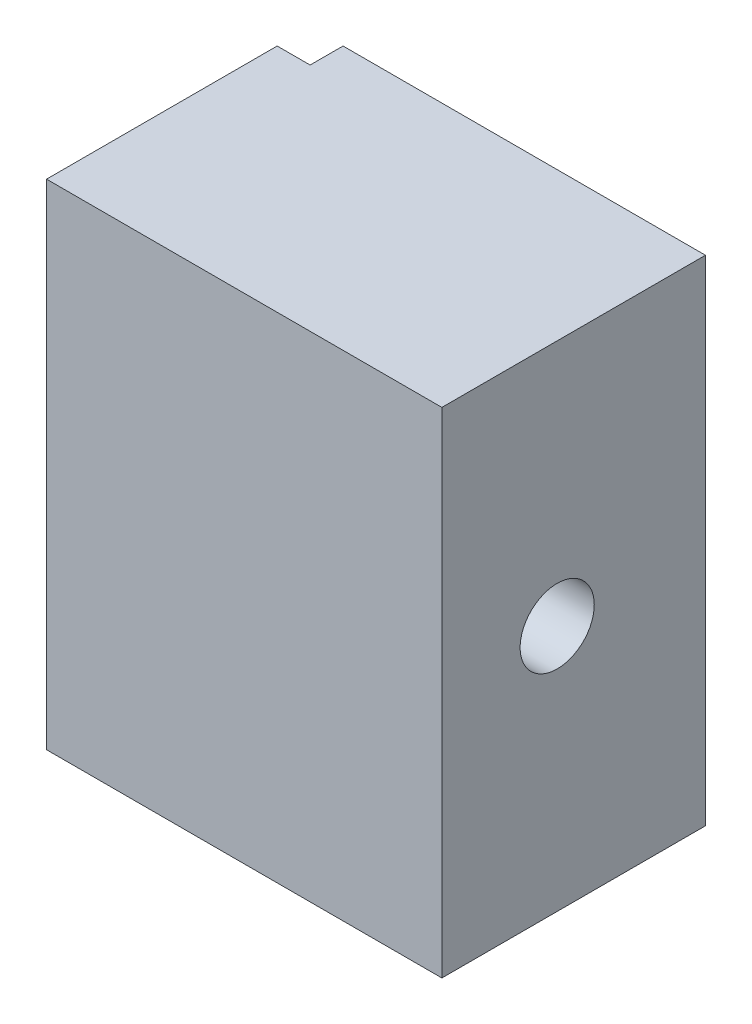
from build123d import *

# Parameters (mm, degrees)
SKETCH1_W            = 16
SKETCH1_H            = 30
BOSS_EXTRUDE1_DEPTH  = 24
SKETCH2_W            = 2
SKETCH2_H            = 30
CUT_EXTRUDE1_DEPTH   = 2
M4_CLEARANCE_HOLE1_D = 4.5


with BuildPart() as part:
    # Sketch1 → Boss-Extrude1 (new body)
    with BuildSketch(Plane(origin=(0, 0, 0), x_dir=(0, 0, -1), z_dir=(1, 0, 0))):
        with Locations((-8, 15)):
            Rectangle(SKETCH1_W, SKETCH1_H)
    extrude(amount=BOSS_EXTRUDE1_DEPTH)

    # Sketch2 → Cut-Extrude1 (cut)
    with BuildSketch(Plane.ZY):
        with Locations((1, 15)):
            Rectangle(SKETCH2_W, SKETCH2_H)
    extrude(amount=-CUT_EXTRUDE1_DEPTH, mode=Mode.SUBTRACT)

    # M4 Clearance Hole1 (through all)
    with Locations(Plane(origin=(24, 0, 0), x_dir=(0, 0, -1), z_dir=(1, 0, 0))):
        with Locations((-9, 15)):
            Hole(M4_CLEARANCE_HOLE1_D / 2)


solid = part.part
